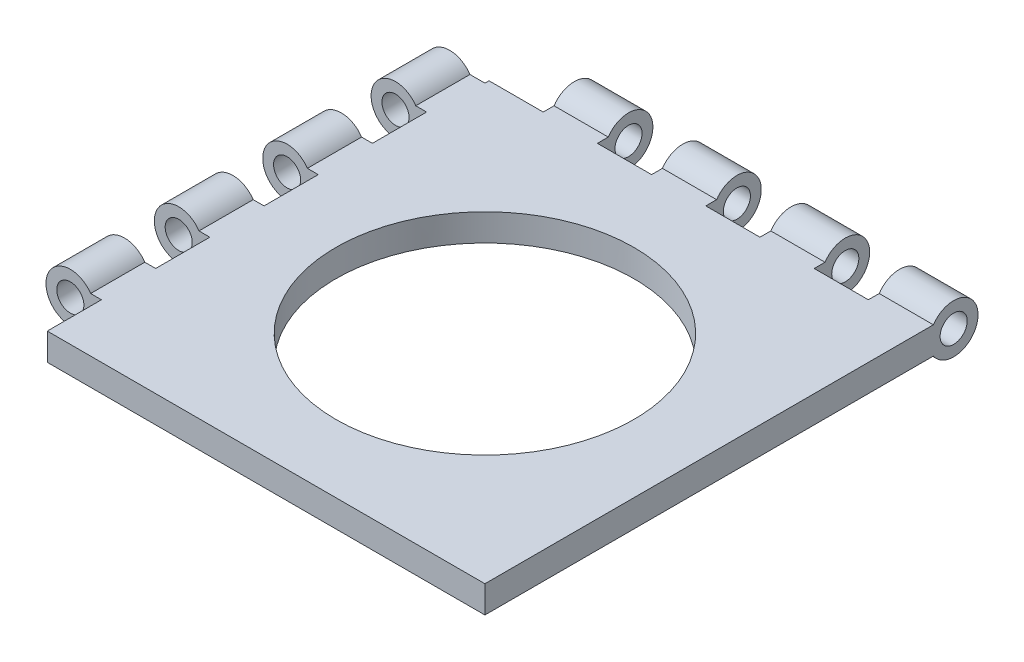
from build123d import *

# Parameters (mm, degrees)
SKETCH1_W                                 = 101.6
SKETCH1_H                                 = 101.6
BASE_EXTRUDE_DEPTH                        = 3.175
SKETCH9_R                                 = 34.925
CENTER_HOLE_DEPTH                         = 29.575
SKETCH2_R                                 = 5.715
SKETCH2_R_2                               = 3.175
LEFT_HINGE_BASE_DEPTH                     = 50.8
LEFT_HINGE_BASE_DEPTH_BACK                = 50.8
SKETCH2_3_R                               = 3.175
LEFT_HINGE_CUT_DEPTH                      = 50.8
LEFT_HINGE_CUT_DEPTH_BACK                 = 50.8
SKETCH3_W                                 = 101.6
SKETCH3_H                                 = 6.35
LEFT_HINGE_EXTENSION_DEPTH                = 3.503095
SKETCH4_R                                 = 5.715
SKETCH4_R_2                               = 3.175
BACK_HINGE_BASE_DEPTH                     = 50.8
BACK_HINGE_BASE_DEPTH_BACK                = 50.8
SKETCH4_3_R                               = 3.175
BACK_HINGE_CUT_DEPTH                      = 50.8
BACK_HINGE_CUT_DEPTH_BACK                 = 50.8
SKETCH7_W                                 = 101.6
SKETCH7_H                                 = 6.35
BACK_HINGE_EXTENSION_DEPTH                = 3.503095
SKETCH8_W                                 = 13.006904881
SKETCH8_H                                 = 12.7
HINGE_CUT_LEFT_DEPTH                      = 32.115
HINGE_CUT_LEFT_LPATTERN_COUNT             = 4
HINGE_CUT_LEFT_LPATTERN_PITCH             = 25.4
HINGE_CUT_BACK_CIRPATTERN_COUNT           = 2
HINGE_CUT_BACK_CIRPATTERN_ANGLE           = 90
HINGE_CUT_BACK_CIRPATTERN_COPY_1_SKETCH_W = 13.006904881
HINGE_CUT_BACK_CIRPATTERN_COPY_1_SKETCH_H = 12.7
HINGE_CUT_BACK_CIRPATTERN_COPY_1_DEPTH    = 32.115
HINGE_CUT_BACK_CIRPATTERN_COPY_2_SKETCH_W = 13.006904881
HINGE_CUT_BACK_CIRPATTERN_COPY_2_SKETCH_H = 12.7
HINGE_CUT_BACK_CIRPATTERN_COPY_2_DEPTH    = 32.115
HINGE_CUT_BACK_CIRPATTERN_COPY_3_SKETCH_W = 13.006904881
HINGE_CUT_BACK_CIRPATTERN_COPY_3_SKETCH_H = 12.7
HINGE_CUT_BACK_CIRPATTERN_COPY_3_DEPTH    = 32.115
CIRPATTERN2_COPY_1_SKETCH_W               = 13.006904881
CIRPATTERN2_COPY_1_SKETCH_H               = 12.7
CIRPATTERN2_COPY_1_DEPTH                  = 32.115
CIRPATTERN2_COPY_2_SKETCH_W               = 13.006904881
CIRPATTERN2_COPY_2_SKETCH_H               = 12.7
CIRPATTERN2_COPY_2_DEPTH                  = 32.115
CIRPATTERN2_COPY_3_SKETCH_W               = 13.006904881
CIRPATTERN2_COPY_3_SKETCH_H               = 12.7
CIRPATTERN2_COPY_3_DEPTH                  = 32.115
CIRPATTERN2_COPY_4_SKETCH_W               = 13.006904881
CIRPATTERN2_COPY_4_SKETCH_H               = 12.7
CIRPATTERN2_COPY_4_DEPTH                  = 32.115


with BuildPart() as part:
    # Sketch1 → Base Extrude (new body, symmetric)
    with BuildSketch(Plane(origin=(0, 0, 0), x_dir=(1, 0, 0), z_dir=(0, 1, 0))):
        Rectangle(SKETCH1_W, SKETCH1_H)
    extrude(amount=BASE_EXTRUDE_DEPTH, both=True)

    # Sketch9 → Center Hole (cut, through all)
    with BuildSketch(Plane(origin=(0, 25.4, 0), x_dir=(-1, 0, 0), z_dir=(0, 1, 0))):
        with Locations(Location((0, 0, 0), (0, 0, 90))):  # turned: the seam where the file's is
            Circle(SKETCH9_R)
    extrude(amount=-CENTER_HOLE_DEPTH, mode=Mode.SUBTRACT)



with BuildPart() as body_2:
    # Sketch2 → Left Hinge Base (new body, two sides)
    with BuildSketch(Plane.XY) as left_hinge_base_sk:
        with Locations((-59.055, 0)):
            Circle(SKETCH2_R)
        with Locations((-59.055, 0)):
            Circle(SKETCH2_R_2, mode=Mode.SUBTRACT)
        with Locations((-59.055, 0)):
            Circle(SKETCH2_R_2)
    extrude(amount=LEFT_HINGE_BASE_DEPTH)
    extrude(left_hinge_base_sk.sketch, amount=-LEFT_HINGE_BASE_DEPTH_BACK)

    # Sketch2_3 → Left Hinge Cut (cut, two sides)
    with BuildSketch(Plane.XY) as left_hinge_cut_sk:
        with Locations((-59.055, 0)):
            Circle(SKETCH2_3_R)
    extrude(amount=LEFT_HINGE_CUT_DEPTH, mode=Mode.SUBTRACT)
    extrude(left_hinge_cut_sk.sketch, amount=-LEFT_HINGE_CUT_DEPTH_BACK, mode=Mode.SUBTRACT)


with BuildPart() as part_1:
    add(part.part)

    add(body_2.part)  # Left Hinge Extension merges body 2
    # Sketch3 → Left Hinge Extension (add)
    with BuildSketch(Plane.ZY.offset(50.8)):
        Rectangle(SKETCH3_W, SKETCH3_H)
    extrude(amount=LEFT_HINGE_EXTENSION_DEPTH)



with BuildPart() as body_2_2:
    # Sketch4 → Back Hinge Base (new body, two sides)
    with BuildSketch(Plane(origin=(0, 0, 0), x_dir=(0, 0, -1), z_dir=(1, 0, 0))) as back_hinge_base_sk:
        with Locations((59.055, 0)):
            Circle(SKETCH4_R)
        with Locations((59.055, 0)):
            Circle(SKETCH4_R_2, mode=Mode.SUBTRACT)
        with Locations((59.055, 0)):
            Circle(SKETCH4_R_2)
    extrude(amount=BACK_HINGE_BASE_DEPTH)
    extrude(back_hinge_base_sk.sketch, amount=-BACK_HINGE_BASE_DEPTH_BACK)

    # Sketch4_3 → Back Hinge Cut (cut, two sides)
    with BuildSketch(Plane(origin=(0, 0, 0), x_dir=(0, 0, -1), z_dir=(1, 0, 0))) as back_hinge_cut_sk:
        with Locations((59.055, 0)):
            Circle(SKETCH4_3_R)
    extrude(amount=BACK_HINGE_CUT_DEPTH, mode=Mode.SUBTRACT)
    extrude(back_hinge_cut_sk.sketch, amount=-BACK_HINGE_CUT_DEPTH_BACK, mode=Mode.SUBTRACT)


with BuildPart() as part_2:
    add(part_1.part)

    add(body_2_2.part)  # Back Hinge Extension merges body 2 2
    # Sketch7 → Back Hinge Extension (add)
    with BuildSketch(Plane(origin=(0, 0, -50.8), x_dir=(-1, 0, 0), z_dir=(0, 0, -1))):
        Rectangle(SKETCH7_W, SKETCH7_H)
    extrude(amount=BACK_HINGE_EXTENSION_DEPTH)

    # Sketch8 → Hinge Cut Left (cut, through all)
    with BuildSketch(Plane(origin=(0, 25.4, 0), x_dir=(-1, 0, 0), z_dir=(0, 1, 0))):
        with Locations((58.26654756, 44.45)):
            Rectangle(SKETCH8_W, SKETCH8_H)
    hinge_cut_left = extrude(amount=-HINGE_CUT_LEFT_DEPTH, mode=Mode.SUBTRACT)

    # Hinge Cut Left LPattern: Hinge Cut Left ×4
    with Locations(*[(0, 0, -i * HINGE_CUT_LEFT_LPATTERN_PITCH) for i in range(1, HINGE_CUT_LEFT_LPATTERN_COUNT)]):
        add(hinge_cut_left, mode=Mode.SUBTRACT)

    # Hinge Cut Back CirPattern: Hinge Cut Left ×2 about axis
    hinge_cut_back_cirpattern_axis = Axis((0, 0, 0), (0, -1, 0))
    for i in range(1, HINGE_CUT_BACK_CIRPATTERN_COUNT):
        add(hinge_cut_left.rotate(hinge_cut_back_cirpattern_axis, i * HINGE_CUT_BACK_CIRPATTERN_ANGLE / (HINGE_CUT_BACK_CIRPATTERN_COUNT - 1)), mode=Mode.SUBTRACT)

    # Hinge Cut Back CirPattern copy 1 sketch → Hinge Cut Back CirPattern copy 1 (cut, through all)
    with BuildSketch(Plane(origin=(25.4, 25.4, 0), x_dir=(0, 0, -1), z_dir=(0, 1, 0))):
        with Locations((58.26654756, 44.45)):
            Rectangle(HINGE_CUT_BACK_CIRPATTERN_COPY_1_SKETCH_W, HINGE_CUT_BACK_CIRPATTERN_COPY_1_SKETCH_H)
    extrude(amount=-HINGE_CUT_BACK_CIRPATTERN_COPY_1_DEPTH, mode=Mode.SUBTRACT)

    # Hinge Cut Back CirPattern copy 2 sketch → Hinge Cut Back CirPattern copy 2 (cut, through all)
    with BuildSketch(Plane(origin=(50.8, 25.4, 0), x_dir=(0, 0, -1), z_dir=(0, 1, 0))):
        with Locations((58.26654756, 44.45)):
            Rectangle(HINGE_CUT_BACK_CIRPATTERN_COPY_2_SKETCH_W, HINGE_CUT_BACK_CIRPATTERN_COPY_2_SKETCH_H)
    extrude(amount=-HINGE_CUT_BACK_CIRPATTERN_COPY_2_DEPTH, mode=Mode.SUBTRACT)

    # Hinge Cut Back CirPattern copy 3 sketch → Hinge Cut Back CirPattern copy 3 (cut, through all)
    with BuildSketch(Plane(origin=(76.2, 25.4, 0), x_dir=(0, 0, -1), z_dir=(0, 1, 0))):
        with Locations((58.26654756, 44.45)):
            Rectangle(HINGE_CUT_BACK_CIRPATTERN_COPY_3_SKETCH_W, HINGE_CUT_BACK_CIRPATTERN_COPY_3_SKETCH_H)
    extrude(amount=-HINGE_CUT_BACK_CIRPATTERN_COPY_3_DEPTH, mode=Mode.SUBTRACT)

    # CirPattern2 copy 1 sketch → CirPattern2 copy 1 (cut, through all)
    with BuildSketch(Plane(origin=(0, 25.4, 25.4), x_dir=(1, 0, 0), z_dir=(0, 1, 0))):
        with Locations((58.26654756, 44.45)):
            Rectangle(CIRPATTERN2_COPY_1_SKETCH_W, CIRPATTERN2_COPY_1_SKETCH_H)
    extrude(amount=-CIRPATTERN2_COPY_1_DEPTH, mode=Mode.SUBTRACT)

    # CirPattern2 copy 2 sketch → CirPattern2 copy 2 (cut, through all)
    with BuildSketch(Plane(origin=(0, 25.4, 50.8), x_dir=(1, 0, 0), z_dir=(0, 1, 0))):
        with Locations((58.26654756, 44.45)):
            Rectangle(CIRPATTERN2_COPY_2_SKETCH_W, CIRPATTERN2_COPY_2_SKETCH_H)
    extrude(amount=-CIRPATTERN2_COPY_2_DEPTH, mode=Mode.SUBTRACT)

    # CirPattern2 copy 3 sketch → CirPattern2 copy 3 (cut, through all)
    with BuildSketch(Plane(origin=(0, 25.4, 76.2), x_dir=(1, 0, 0), z_dir=(0, 1, 0))):
        with Locations((58.26654756, 44.45)):
            Rectangle(CIRPATTERN2_COPY_3_SKETCH_W, CIRPATTERN2_COPY_3_SKETCH_H)
    extrude(amount=-CIRPATTERN2_COPY_3_DEPTH, mode=Mode.SUBTRACT)

    # CirPattern2 copy 4 sketch → CirPattern2 copy 4 (cut, through all)
    with BuildSketch(Plane(origin=(0, 25.4, 0), x_dir=(1, 0, 0), z_dir=(0, 1, 0))):
        with Locations((58.26654756, 44.45)):
            Rectangle(CIRPATTERN2_COPY_4_SKETCH_W, CIRPATTERN2_COPY_4_SKETCH_H)
    extrude(amount=-CIRPATTERN2_COPY_4_DEPTH, mode=Mode.SUBTRACT)


solid = part_2.part
